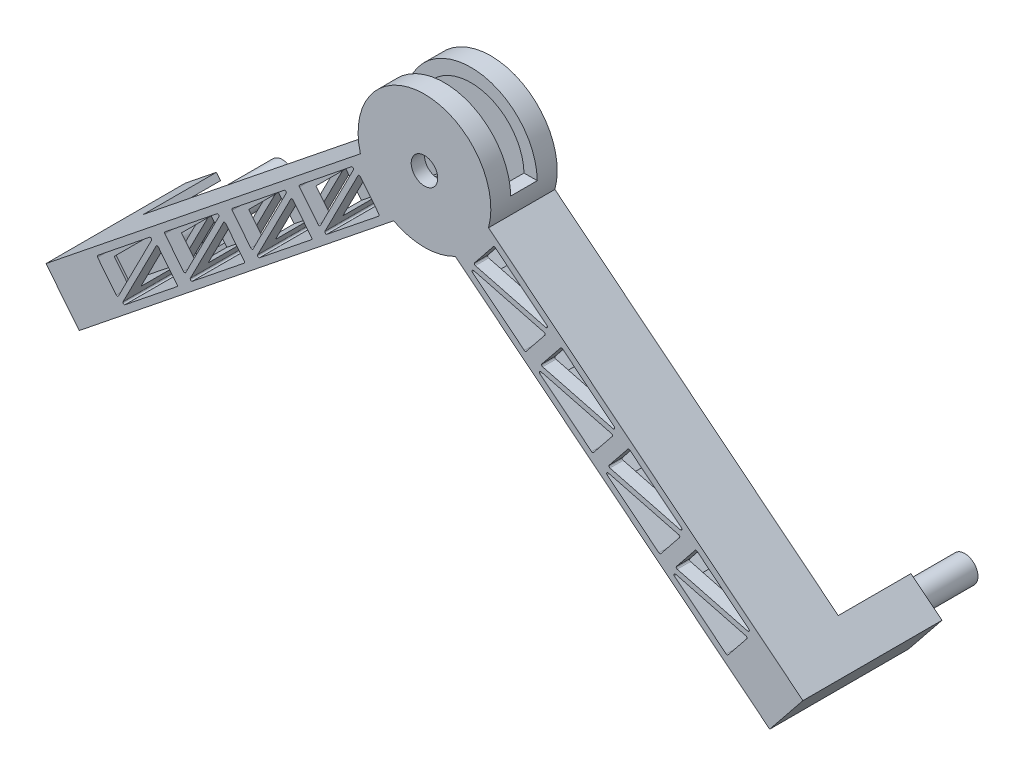
from build123d import *

# Parameters (mm, degrees)
BOSS_EXTRUDE1_DEPTH = 50
SHELL1_T            = -10
SKETCH2_R           = 10
CUT_EXTRUDE1_DEPTH  = 50
SKETCH5_W           = 100
SKETCH5_H           = 20
CUT_EXTRUDE2_DEPTH  = 50
SKETCH6_W           = 30
SKETCH6_H           = 20
CUT_EXTRUDE3_DEPTH  = 50
SKETCH7_W           = 4.757319218
SKETCH7_H           = 40
BOSS_EXTRUDE2_DEPTH = 5
BOSS_EXTRUDE3_DEPTH = 100
BOSS_EXTRUDE4_DEPTH = 54.757319
SKETCH12_W          = 9.972991782
SKETCH12_H          = 40
BOSS_EXTRUDE5_DEPTH = 5
BOSS_EXTRUDE6_DEPTH = 95
BOSS_EXTRUDE7_DEPTH = 54.972992
CUT_EXTRUDE4_DEPTH  = 95
SKETCH16_R          = 10
BOSS_EXTRUDE8_DEPTH = 100
SKETCH18_R          = 10
BOSS_EXTRUDE9_DEPTH = 100


with BuildPart() as part:
    # Sketch1 → Boss-Extrude1 (new body)
    with BuildSketch(Plane.XY):
        with BuildLine():
            Line((-187.116228399, 0), (45.852765534, 186.921335305))
            ThreePointArc((45.852765534, 186.921335305), (94.111946316, 250), (142.371127099, 186.921335305))
            Line((142.371127099, 186.921335305), (375.340121031, 0))
            Line((375.340121031, 0), (350.307747828, -31.199043123))
            Line((350.307747828, -31.199043123), (117.338753895, 155.722292181))
            ThreePointArc((117.338753895, 155.722292181), (94.111946316, 150), (70.885138737, 155.722292181))
            Line((70.885138737, 155.722292181), (-162.083855196, -31.199043123))
            Line((-162.083855196, -31.199043123), (-187.116228399, 0))
        make_face()
    extrude(amount=BOSS_EXTRUDE1_DEPTH)

    # Shell1
    shell1_openings = [part.faces().sort_by_distance(p)[0] for p in [
        (-174.600041797, -15.599521562, 25),
    ]]
    offset(amount=SHELL1_T, openings=shell1_openings, kind=Kind.INTERSECTION)

    # Sketch2 → Cut-Extrude1 (cut)
    with BuildSketch(Plane.XY.offset(50)):
        with Locations((94.111946316, 200)):
            Circle(SKETCH2_R)
    extrude(amount=-CUT_EXTRUDE1_DEPTH, mode=Mode.SUBTRACT)

    # Sketch5 → Cut-Extrude2 (cut)
    with BuildSketch(Plane(origin=(0, 251, 0), x_dir=(1, 0, 0), z_dir=(0, 1, 0))):
        with Locations((94.111946316, -25)):
            Rectangle(SKETCH5_W, SKETCH5_H)
    extrude(amount=-CUT_EXTRUDE2_DEPTH, mode=Mode.SUBTRACT)

    # Sketch6 → Cut-Extrude3 (cut)
    with BuildSketch(Plane(origin=(228.342922838, -183.209633711, 0), x_dir=(0, 0, -1), z_dir=(0.779976078, -0.62580933, 0))):
        with Locations((-25, 214.891349694)):
            Rectangle(SKETCH6_W, SKETCH6_H)
    extrude(amount=-CUT_EXTRUDE3_DEPTH, mode=Mode.SUBTRACT)

    # Sketch7 → Boss-Extrude2 (add)
    with BuildSketch(Plane(origin=(228.342922838, -183.209633711, 0), x_dir=(0, 0, -1), z_dir=(0.779976078, -0.62580933, 0))):
        with Locations((-2.378659609, 214.891349694)):
            Rectangle(SKETCH7_W, SKETCH7_H)
    extrude(amount=BOSS_EXTRUDE2_DEPTH)

    # Sketch8 → Boss-Extrude3 (add)
    with BuildSketch(Plane.XY.offset(4.757319218)):
        Polygon((375.340121031, 0), (350.307747828, -31.199043123), (354.207628218, -34.328089774), (379.240001422, -3.12904665), align=None)
    extrude(amount=BOSS_EXTRUDE3_DEPTH)

    # Sketch9 → Boss-Extrude4 (add)
    with BuildSketch(Plane.XY.offset(50)):
        Polygon((375.340121031, 0), (355.840719079, 15.645233252), (352.711672429, 11.745352862), (372.211074381, -3.89988039), align=None)
        Polygon((350.307747828, -31.199043123), (330.808345876, -15.553809872), (333.937392526, -11.653929481), (353.436794478, -27.299162733), align=None)
    extrude(amount=BOSS_EXTRUDE4_DEPTH)

    # Sketch12 → Boss-Extrude5 (add)
    with BuildSketch(Plane(origin=(-113.834530627, -91.334482368, 0), x_dir=(0, 0, 1), z_dir=(-0.779976078, -0.62580933, 0))):
        with Locations((4.986495891, 97.099081541)):
            Rectangle(SKETCH12_W, SKETCH12_H)
    extrude(amount=BOSS_EXTRUDE5_DEPTH)

    # Sketch13 → Boss-Extrude6 (add)
    with BuildSketch(Plane.XY.offset(9.972991782)):
        Polygon((-162.083855196, -31.199043123), (-187.116228399, 0), (-191.016108789, -3.12904665), (-165.983735586, -34.328089774), align=None)
    extrude(amount=BOSS_EXTRUDE6_DEPTH)

    # Sketch14 → Boss-Extrude7 (add)
    with BuildSketch(Plane.XY.offset(50)):
        Polygon((-187.116228399, 0), (-167.616826447, 15.645233252), (-164.487779796, 11.745352862), (-183.987181748, -3.89988039), align=None)
        Polygon((-162.083855196, -31.199043123), (-165.212901846, -27.299162733), (-145.713499894, -11.653929481), (-142.584453244, -15.553809872), align=None)
    extrude(amount=BOSS_EXTRUDE7_DEPTH)

    # Sketch15 → Cut-Extrude4 (cut)
    with BuildSketch(Plane.XY.offset(50)):
        with BuildLine():
            Line((-152.162329295, 20.352516735), (-138.10997348, 2.838394062))
            ThreePointArc((-138.10997348, 2.838394062), (-137.22835262, 2.469382635), (-136.439576622, 3.009065133))
            Line((-136.439576622, 3.009065133), (-111.493128533, 51.813654309))
            ThreePointArc((-111.493128533, 51.813654309), (-111.751978524, 53.044110786), (-113.009358643, 53.048768647))
            Line((-113.009358643, 53.048768647), (-152.008162547, 21.758302143))
            ThreePointArc((-152.008162547, 21.758302143), (-152.376393612, 21.087338418), (-152.162329295, 20.352516735))
        make_face()
        with BuildLine():
            Line((-106.340954265, 50.007446869), (-92.28859845, 32.493324197))
            ThreePointArc((-92.28859845, 32.493324197), (-92.074534133, 31.758502514), (-92.442765198, 31.087538789))
            Line((-92.442765198, 31.087538789), (-131.441569102, -0.202927715))
            ThreePointArc((-131.441569102, -0.202927715), (-132.698949221, -0.198269855), (-132.957799212, 1.032186622))
            Line((-132.957799212, 1.032186622), (-108.011351123, 49.836775799))
            ThreePointArc((-108.011351123, 49.836775799), (-107.222575125, 50.376458296), (-106.340954265, 50.007446869))
        make_face()
        with BuildLine():
            Line((-62.310913567, 93.726375102), (-101.309717471, 62.435908598))
            ThreePointArc((-101.309717471, 62.435908598), (-101.677948536, 61.764944873), (-101.463884219, 61.03012319))
            Line((-101.463884219, 61.03012319), (-87.411528404, 43.516000517))
            ThreePointArc((-87.411528404, 43.516000517), (-86.529907544, 43.14698909), (-85.741131546, 43.686671588))
            Line((-85.741131546, 43.686671588), (-60.794683457, 92.491260764))
            ThreePointArc((-60.794683457, 92.491260764), (-61.053533448, 93.721717241), (-62.310913567, 93.726375102))
        make_face()
        with BuildLine():
            Line((-82.259354137, 41.709793077), (-57.312906048, 90.514382254))
            ThreePointArc((-57.312906048, 90.514382254), (-56.524130049, 91.054064751), (-55.64250919, 90.685053325))
            Line((-55.64250919, 90.685053325), (-41.590153374, 73.170930652))
            ThreePointArc((-41.590153374, 73.170930652), (-41.376089058, 72.436108969), (-41.744320122, 71.765145244))
            Line((-41.744320122, 71.765145244), (-80.743124027, 40.47467874))
            ThreePointArc((-80.743124027, 40.47467874), (-82.000504146, 40.4793366), (-82.259354137, 41.709793077))
        make_face()
        with BuildLine():
            Line((-11.612468491, 134.403981557), (-50.611272396, 103.113515053))
            ThreePointArc((-50.611272396, 103.113515053), (-50.979503461, 102.442551328), (-50.765439144, 101.707729645))
            Line((-50.765439144, 101.707729645), (-36.713083328, 84.193606972))
            ThreePointArc((-36.713083328, 84.193606972), (-35.831462469, 83.824595545), (-35.042686471, 84.364278043))
            Line((-35.042686471, 84.364278043), (-10.096238381, 133.168867219))
            ThreePointArc((-10.096238381, 133.168867219), (-10.355088372, 134.399323696), (-11.612468491, 134.403981557))
        make_face()
        with BuildLine():
            Line((-31.560909061, 82.387399532), (-6.614460972, 131.191988709))
            ThreePointArc((-6.614460972, 131.191988709), (-5.825684974, 131.731671206), (-4.944064114, 131.36265978))
            Line((-4.944064114, 131.36265978), (9.108291701, 113.848537107))
            ThreePointArc((9.108291701, 113.848537107), (9.322356018, 113.113715424), (8.954124953, 112.442751699))
            Line((8.954124953, 112.442751699), (-30.044678951, 81.152285195))
            ThreePointArc((-30.044678951, 81.152285195), (-31.30205907, 81.156943055), (-31.560909061, 82.387399532))
        make_face()
        with BuildLine():
            Line((39.085976584, 175.081588012), (0.08717268, 143.791121508))
            ThreePointArc((0.08717268, 143.791121508), (-0.281058385, 143.120157783), (-0.066994068, 142.3853361))
            Line((-0.066994068, 142.3853361), (13.985361747, 124.871213427))
            ThreePointArc((13.985361747, 124.871213427), (14.866982607, 124.502202), (15.655758605, 125.041884498))
            Line((15.655758605, 125.041884498), (40.602206694, 173.846473674))
            ThreePointArc((40.602206694, 173.846473674), (40.343356703, 175.076930151), (39.085976584, 175.081588012))
        make_face()
        with BuildLine():
            Line((19.137536015, 123.065005987), (44.083984104, 171.869595164))
            ThreePointArc((44.083984104, 171.869595164), (44.872760102, 172.409277661), (45.754380962, 172.040266235))
            Line((45.754380962, 172.040266235), (59.806736777, 154.526143562))
            ThreePointArc((59.806736777, 154.526143562), (60.020801094, 153.791321879), (59.652570029, 153.120358154))
            Line((59.652570029, 153.120358154), (20.653766124, 121.82989165))
            ThreePointArc((20.653766124, 121.82989165), (19.396386006, 121.83454951), (19.137536015, 123.065005987))
        make_face()
        with BuildLine():
            Line((322.863560685, -1.486813452), (336.9159165, 16.027309221))
            ThreePointArc((336.9159165, 16.027309221), (337.085087888, 16.967950393), (336.387284466, 17.621016361))
            Line((336.387284466, 17.621016361), (283.336124747, 31.397360193))
            ThreePointArc((283.336124747, 31.397360193), (282.191012363, 30.877991261), (282.458971372, 29.649486304))
            Line((282.458971372, 29.649486304), (321.457775277, -1.6409802))
            ThreePointArc((321.457775277, -1.6409802), (322.19259696, -1.855044517), (322.863560685, -1.486813452))
        make_face()
        with BuildLine():
            Line((338.439741637, 23.196354627), (299.440937733, 54.486821131))
            ThreePointArc((299.440937733, 54.486821131), (298.70611605, 54.700885448), (298.035152325, 54.332654383))
            Line((298.035152325, 54.332654383), (283.982796509, 36.818531711))
            ThreePointArc((283.982796509, 36.818531711), (283.813625122, 35.877890538), (284.511428543, 35.22482457))
            Line((284.511428543, 35.22482457), (337.562588263, 21.448480739))
            ThreePointArc((337.562588263, 21.448480739), (338.707700647, 21.967849671), (338.439741637, 23.196354627))
        make_face()
        with BuildLine():
            Line((233.814614905, 75.901122051), (286.865774625, 62.124778219))
            ThreePointArc((286.865774625, 62.124778219), (288.010887009, 62.644147151), (287.742927999, 63.872652108))
            Line((287.742927999, 63.872652108), (248.744124095, 95.163118612))
            ThreePointArc((248.744124095, 95.163118612), (248.009302411, 95.377182929), (247.338338686, 95.008951864))
            Line((247.338338686, 95.008951864), (233.285982871, 77.494829191))
            ThreePointArc((233.285982871, 77.494829191), (233.116811484, 76.554188019), (233.814614905, 75.901122051))
        make_face()
        with BuildLine():
            Line((231.762157734, 70.325783785), (270.760961639, 39.035317281))
            ThreePointArc((270.760961639, 39.035317281), (271.495783322, 38.821252964), (272.166747047, 39.189484029))
            Line((272.166747047, 39.189484029), (286.219102862, 56.703606701))
            ThreePointArc((286.219102862, 56.703606701), (286.388274249, 57.644247874), (285.690470828, 58.297313842))
            Line((285.690470828, 58.297313842), (232.639311109, 72.073657673))
            ThreePointArc((232.639311109, 72.073657673), (231.494198725, 71.554288741), (231.762157734, 70.325783785))
        make_face()
        with BuildLine():
            Line((183.117801267, 116.577419531), (236.168960986, 102.8010757))
            ThreePointArc((236.168960986, 102.8010757), (237.31407337, 103.320444632), (237.046114361, 104.548949589))
            Line((237.046114361, 104.548949589), (198.047310456, 135.839416092))
            ThreePointArc((198.047310456, 135.839416092), (197.312488773, 136.053480409), (196.641525048, 135.685249344))
            Line((196.641525048, 135.685249344), (182.589169233, 118.171126672))
            ThreePointArc((182.589169233, 118.171126672), (182.419997846, 117.230485499), (183.117801267, 116.577419531))
        make_face()
        with BuildLine():
            Line((181.065344096, 111.002081265), (220.064148, 79.711614761))
            ThreePointArc((220.064148, 79.711614761), (220.798969684, 79.497550444), (221.469933409, 79.865781509))
            Line((221.469933409, 79.865781509), (235.522289224, 97.379904182))
            ThreePointArc((235.522289224, 97.379904182), (235.691460611, 98.320545354), (234.99365719, 98.973611322))
            Line((234.99365719, 98.973611322), (181.94249747, 112.749955154))
            ThreePointArc((181.94249747, 112.749955154), (180.797385086, 112.230586222), (181.065344096, 111.002081265))
        make_face()
        with BuildLine():
            Line((132.420987629, 157.253717012), (185.472147348, 143.477373181))
            ThreePointArc((185.472147348, 143.477373181), (186.617259732, 143.996742113), (186.349300723, 145.225247069))
            Line((186.349300723, 145.225247069), (147.350496818, 176.515713573))
            ThreePointArc((147.350496818, 176.515713573), (146.615675135, 176.72977789), (145.94471141, 176.361546825))
            Line((145.94471141, 176.361546825), (131.892355595, 158.847424152))
            ThreePointArc((131.892355595, 158.847424152), (131.723184208, 157.90678298), (132.420987629, 157.253717012))
        make_face()
        with BuildLine():
            Line((130.368530458, 151.678378746), (169.367334362, 120.387912242))
            ThreePointArc((169.367334362, 120.387912242), (170.102156045, 120.173847925), (170.77311977, 120.54207899))
            Line((170.77311977, 120.54207899), (184.825475586, 138.056201662))
            ThreePointArc((184.825475586, 138.056201662), (184.994646973, 138.996842835), (184.296843552, 139.649908803))
            Line((184.296843552, 139.649908803), (131.245683832, 153.426252634))
            ThreePointArc((131.245683832, 153.426252634), (130.100571448, 152.906883702), (130.368530458, 151.678378746))
        make_face()
    extrude(amount=-CUT_EXTRUDE4_DEPTH, mode=Mode.SUBTRACT)

    # Sketch16 → Boss-Extrude8 (add)
    with BuildSketch(Plane.XY.offset(50)):
        with Locations((-162.900400626, -6.212381611)):
            Circle(SKETCH16_R)
    extrude(amount=BOSS_EXTRUDE8_DEPTH)

    # Sketch18 → Boss-Extrude9 (add)
    with BuildSketch(Plane.XY.offset(50)):
        with Locations((351.124293258, -6.212381611)):
            Circle(SKETCH18_R)
    extrude(amount=BOSS_EXTRUDE9_DEPTH)


with BuildPart() as body_2:
    # Mirror2: mirrored copy
    add(part.part.mirror(Plane.XY))


solid = body_2.part
